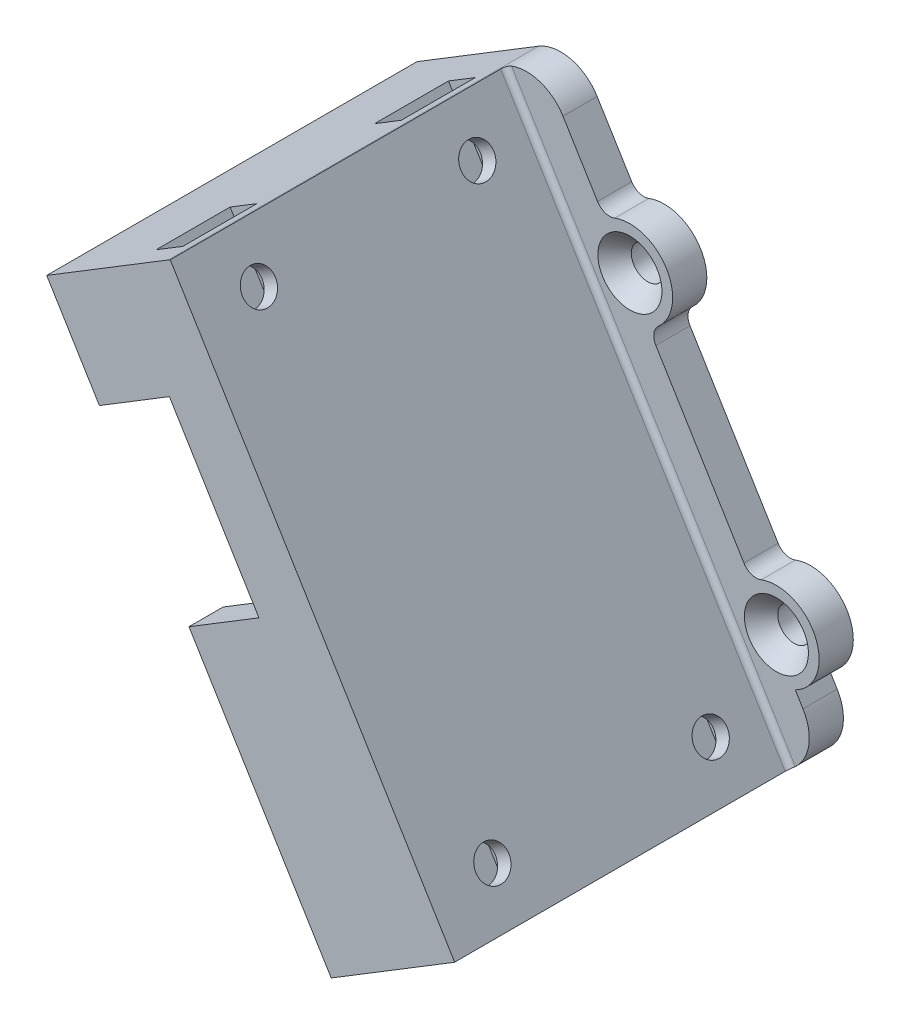
from build123d import *

# Parameters (mm, degrees)
BOSS_EXTRUDE1_DEPTH                               = 3.048
BOSS_EXTRUDE2_DEPTH                               = 29.971999999999998
BOSS_EXTRUDE3_DEPTH                               = 3.048
BOSS_EXTRUDE4_DEPTH                               = 3.048
SKETCH13_W                                        = 29.972
SKETCH13_H                                        = 48.7
BOSS_EXTRUDE5_DEPTH                               = 3.048
CSK_FOR_4_FLAT_HEAD_MACHINE_SCREW_100_D           = 2.9464
CSK_FOR_4_FLAT_HEAD_MACHINE_SCREW_100_CSINK_D     = 5.715
CSK_FOR_4_FLAT_HEAD_MACHINE_SCREW_100_CSINK_ANGLE = 100
CUT_EXTRUDE1_DEPTH                                = 1.397
CUT_EXTRUDE1_DEPTH_BACK                           = 1.397
SKETCH15_R                                        = 9.184035329670005
SKETCH15_R_2                                      = 8.124741076595411
SKETCH15_R_3                                      = 8.201451240556812
SKETCH15_R_4                                      = 5.810172256980604
BOSS_EXTRUDE6_DEPTH                               = 3.048
CSK_FOR_4_FLAT_HEAD_MACHINE_SCREW1_AT_2_COUNT     = 2
CSK_FOR_4_FLAT_HEAD_MACHINE_SCREW1_AT_2_PITCH     = 35.474094707842795
CSK_FOR_4_FLAT_HEAD_MACHINE_SCREW1_AT_3_COUNT     = 2
CSK_FOR_4_FLAT_HEAD_MACHINE_SCREW1_AT_3_PITCH     = 43.70753982500484
CSK_FOR_4_FLAT_HEAD_MACHINE_SCREW1_AT_4_COUNT     = 2
CSK_FOR_4_FLAT_HEAD_MACHINE_SCREW1_AT_4_PITCH     = 25.069264350610375
CUT_EXTRUDE2_DEPTH                                = 3.048
FILLET3_R                                         = 3.8099999999999996
FILLET4_R                                         = 1.27
SKETCH21_W                                        = 2.540000000000001
SKETCH21_H                                        = 33.02
CUT_EXTRUDE3_DEPTH                                = 77.47
FILLET5_R                                         = 0.508
FILLET6_R                                         = 0.508
SKETCH22_W                                        = 123.04970813102194
SKETCH22_H                                        = 134.7131875745612
CUT_EXTRUDE4_DEPTH                                = 77.47


with BuildPart() as part:
    # Sketch2 → Boss-Extrude1 (new body)
    with BuildSketch(Plane.XY):
        Polygon((-47.58059551455695, 48.12489153745831), (-22.21147896413696, 6.554494312375088), (5.701292889255674, 23.58878817682547), (-19.667823661164306, 65.1591854019087), align=None)
        Polygon((-38.85234269167306, 46.0124042215628), (-20.098991648241444, 15.282747135258976), (-3.0269599336282123, 25.701275492720985), (-21.78031097705982, 56.430932579024805), align=None, mode=Mode.SUBTRACT)
    extrude(amount=BOSS_EXTRUDE1_DEPTH)

    # Sketch3 → Boss-Extrude2 (add)
    with BuildSketch(Plane.XY.offset(3.048)):
        Polygon((2.4490708476218597, 21.604058524728963), (-22.920045702798127, 63.17445574981219), (-44.328373472923126, 50.10962118955482), (-18.95925692250314, 8.539223964471608), align=None)
        Polygon((-38.85234269167306, 46.0124042215628), (-20.098991648241444, 15.282747135258976), (-3.0269599336282087, 25.701275492720985), (-21.78031097705982, 56.430932579024805), align=None, mode=Mode.SUBTRACT)
    extrude(amount=BOSS_EXTRUDE2_DEPTH)

    # Sketch4 → Boss-Extrude3 (add)
    with BuildSketch(Plane.XY.offset(33.02)):
        Polygon((-38.85234269167306, 46.0124042215628), (-37.46131723814535, 43.733039051773666), (-20.389285523532113, 54.15156740923567), (-21.78031097705982, 56.430932579024805), align=None)
        Polygon((-29.47566716995725, 30.647575678410885), (-12.403635455344016, 41.0661040358729), (-3.0269599336282087, 25.701275492720985), (-20.098991648241444, 15.282747135258976), align=None)
    extrude(amount=-BOSS_EXTRUDE3_DEPTH)

    # Sketch12 → Boss-Extrude4 (add)
    with BuildSketch(Plane.XY.offset(3.048)):
        Polygon((2.4490708476218597, 21.604058524728963), (5.701292889255674, 23.58878817682547), (8.120429940678708, 25.065112049236276), (-17.248686609741274, 66.6355092743195), (-22.920045702798127, 63.17445574981219), align=None)
    extrude(amount=-BOSS_EXTRUDE4_DEPTH)

    # Sketch13 → Boss-Extrude5 (add)
    with BuildSketch(Plane(origin=(11.391019162328917, 6.95158362794815, 0), x_dir=(0, 0, -1), z_dir=(0.8536015857306615, 0.5209264178731006, 0))):
        with Locations((-18.034000000000002, 41.515472911157566)):
            Rectangle(SKETCH13_W, SKETCH13_H)
    extrude(amount=BOSS_EXTRUDE5_DEPTH)

    # CSK for #4 Flat Head Machine Screw (100)2 (through all)
    with Locations(Plane(origin=(-10.017308607796087, -6.113250932309213, 0), x_dir=(0, 0, 1), z_dir=(-0.8536015857306615, -0.5209264178731007, 0))):
        with Locations((27.397617355, 61.471448289), (7.925915452, 61.471448289), (7.925915452, 21.515515982), (27.397617355, 21.515515982)):
            CounterSinkHole(CSK_FOR_4_FLAT_HEAD_MACHINE_SCREW_100_D / 2, CSK_FOR_4_FLAT_HEAD_MACHINE_SCREW_100_CSINK_D / 2, counter_sink_angle=CSK_FOR_4_FLAT_HEAD_MACHINE_SCREW_100_CSINK_ANGLE)

    # Sketch14 → Cut-Extrude1 (cut, two sides: drawn at the far end of the back side and taken through both)
    with BuildSketch(Plane(origin=(11.607833965104508, 7.083898938087922, 0), x_dir=(0, 0, -1), z_dir=(0.8536015857306615, 0.5209264178731005, 0)).offset(-CUT_EXTRUDE1_DEPTH_BACK)):
        Polygon((-30.697174143874744, 19.61051598216394), (-30.697174143874744, 14.979833054183299), (-24.09806056703731, 14.979833054183299), (-24.09806056703731, 19.610515982163985), (-24.098060567037347, 23.42051598216399), (-27.39761735545604, 25.325515982163957), (-30.697174143874758, 23.420515982163952), align=None)
        Polygon((-27.39761735545604, 57.661448288693826), (-24.098060567037333, 59.56644828869383), (-24.098060567037336, 63.37644828869381), (-24.098060567037336, 70.99644828869384), (-30.69717414387474, 70.99644828869384), (-30.69717414387474, 63.37644828869381), (-30.69717414387474, 59.56644828869381), align=None)
        Polygon((-7.925915451689084, 57.661448288693826), (-4.626358663270381, 59.56644828869382), (-4.626358663270402, 63.37644828869381), (-4.626358663270402, 70.99644828869384), (-11.225472240107786, 70.99644828869384), (-11.225472240107786, 63.376448288693766), (-11.225472240107747, 59.566448288693785), align=None)
        Polygon((-7.925915451689081, 25.325515982163946), (-11.225472240107791, 23.42051598216395), (-11.225472240107791, 19.610515982163946), (-11.225472240107791, 14.979833054183299), (-4.626358663270366, 14.979833054183299), (-4.626358663270366, 19.610515982163953), (-4.6263586632703655, 23.420515982163952), align=None)
    extrude(amount=CUT_EXTRUDE1_DEPTH + CUT_EXTRUDE1_DEPTH_BACK, mode=Mode.SUBTRACT)

    # Sketch15 → Boss-Extrude6 (add)
    with BuildSketch(Plane(origin=(0, 0, 0), x_dir=(-1, 0, 0), z_dir=(0, 0, -1))):
        with Locations((9.758086495919196, 54.36124573948299)):
            Circle(SKETCH15_R)
        with Locations((39.927818301519274, 35.58488100974543)):
            Circle(SKETCH15_R_2)
        with Locations((25.610425726235285, 18.04643091882164)):
            Circle(SKETCH15_R_3)
        with Locations((-3.4576236647063787, 32.70568986323082)):
            Circle(SKETCH15_R_4)
    extrude(amount=-BOSS_EXTRUDE6_DEPTH)

    # Sketch19 → CSK for #4 Flat Head Machine Screw1 (revolve, cut)
    with BuildSketch(Plane(origin=(3.764373982237945, 32.86032278852424, 3.048), x_dir=(0, -1, 0), z_dir=(1, 0, 0))):
        Polygon((0, 0), (-7.5e-16, 3.0480000000000023), (1.4731999999999932, 3.0480000000000023), (1.4731999999999934, 1.59245498611605), (2.857499999999999, -1.73e-15), align=None)
    csk_for_4_flat_head_machine_screw1 = revolve(axis=Axis((3.764373982237945, 32.86032278852424, 9.39799999999999), (0, 0, -1)), mode=Mode.SUBTRACT)

    # CSK for #4 Flat Head Machine Screw1 at 2: CSK for #4 Flat Head Machine Screw1 ×2
    with Locations(*[Vector(-0.8506492202713736, -0.5257336816789507, 0) * (i * CSK_FOR_4_FLAT_HEAD_MACHINE_SCREW1_AT_2_PITCH) for i in range(1, CSK_FOR_4_FLAT_HEAD_MACHINE_SCREW1_AT_2_COUNT)]):
        add(csk_for_4_flat_head_machine_screw1, mode=Mode.SUBTRACT)

    # CSK for #4 Flat Head Machine Screw1 at 3: CSK for #4 Flat Head Machine Screw1 ×2
    with Locations(*[Vector(-0.997755305773639, 0.06696528802709796, 0) * (i * CSK_FOR_4_FLAT_HEAD_MACHINE_SCREW1_AT_3_PITCH) for i in range(1, CSK_FOR_4_FLAT_HEAD_MACHINE_SCREW1_AT_3_COUNT)]):
        add(csk_for_4_flat_head_machine_screw1, mode=Mode.SUBTRACT)

    # CSK for #4 Flat Head Machine Screw1 at 4: CSK for #4 Flat Head Machine Screw1 ×2
    with Locations(*[Vector(-0.5210117203175807, 0.8535495224600124, 0) * (i * CSK_FOR_4_FLAT_HEAD_MACHINE_SCREW1_AT_4_PITCH) for i in range(1, CSK_FOR_4_FLAT_HEAD_MACHINE_SCREW1_AT_4_COUNT)]):
        add(csk_for_4_flat_head_machine_screw1, mode=Mode.SUBTRACT)

    # Sketch20 → Cut-Extrude2 (cut)
    with BuildSketch(Plane(origin=(0, 0, 0), x_dir=(-1, 0, 0), z_dir=(0, 0, -1))):
        with BuildLine():
            Line((14.542293121824187, 62.20075286029573), (11.563953125478477, 57.32037886408755))
            ThreePointArc((11.563953125478477, 57.32037886408755), (6.044784522535942, 56.24291105550805), (7.610320649443919, 50.84186897257834))
            Line((7.610320649443919, 50.84186897257834), (-1.4954062126549716, 35.92102291440944))
            ThreePointArc((-1.4954062126549716, 35.92102291440944), (-7.016596023871767, 34.845052440620755), (-5.448804035753348, 29.442897530407524))
            Line((-5.448804035753348, 29.442897530407524), (-6.484295885760952, 27.746117611303884))
            Line((-6.484295885760952, 27.746117611303884), (-6.762670750549963, 27.28996638176623))
            Line((-6.762670750549963, 27.28996638176623), (-14.061950278269341, 31.74448896114331))
            Line((-14.061950278269341, 31.74448896114331), (8.559037851416688, 68.81174198534737))
            Line((8.559037851416688, 68.81174198534737), (14.542293121824187, 65.16034795406075))
            Line((14.542293121824187, 65.16034795406075), (14.542293121824187, 62.20075286029573))
        make_face()
        Polygon((21.78031097705982, 56.430932579024805), (38.85234269167306, 46.0124042215628), (20.098991648241444, 15.282747135258976), (3.0269599336282123, 25.701275492720985), align=None)
        with BuildLine():
            Line((22.21147896413696, 6.554494312375088), (24.781951964671258, 10.766528400207497))
            ThreePointArc((24.781951964671258, 10.766528400207497), (29.66385906245521, 12.225666721445755), (28.72915433514684, 17.23450177808784))
            Line((28.72915433514684, 17.23450177808784), (38.012718373529104, 32.44675577885475))
            ThreePointArc((38.012718373529104, 32.44675577885475), (43.097277822107074, 33.802481129765034), (41.97793801322115, 38.944252653808825))
            Line((41.97793801322115, 38.944252653808825), (47.58059551455695, 48.12489153745831))
            Line((47.58059551455695, 48.12489153745831), (51.80171473929435, 35.787210781861546))
            Line((51.80171473929435, 35.787210781861546), (47.57680035710003, 5.227667032097241))
            Line((47.57680035710003, 5.227667032097241), (22.21147896413696, 6.554494312375088))
        make_face()
    extrude(amount=-CUT_EXTRUDE2_DEPTH, mode=Mode.SUBTRACT)


with BuildPart() as body_2:
    # of the pieces the cut leaves, the one that is kept (cut_extrude2_keep)
    add(part.part.solids().sort_by_distance((-47.580595515, 48.124891537, 0))[0])

    # Fillet3
    fillet3_edges = [body_2.edges().sort_by_distance(p)[0] for p in [
        (-17.248686609741274, 66.6355092743195, 1.524),
        (-47.58059551455695, 48.12489153745831, 1.524),
        (-22.21147896413696, 6.554494312375088, 1.524),
        (8.120429940678708, 25.065112049236276, 1.524),
    ]]
    fillet(fillet3_edges, radius=FILLET3_R)

    # Fillet4
    fillet4_edges = [body_2.edges().sort_by_distance(p)[0] for p in [
        (1.4954062126549714, 35.92102291440944, 1.524),
        (-24.781951964671258, 10.766528400207495, 1.524),
        (-28.72915433514684, 17.23450177808784, 1.524),
        (-38.0127183735291, 32.44675577885475, 1.524),
        (-41.97793801322115, 38.94425265380882, 1.524),
        (-11.563953125478475, 57.320378864087544, 1.524),
        (-7.610320649443917, 50.84186897257834, 1.524),
    ]]
    fillet(fillet4_edges, radius=FILLET4_R)

    # Sketch21 → Cut-Extrude3 (cut)
    with BuildSketch(Plane(origin=(-8.941948314707059, 14.652474896780824, 0), x_dir=(0.8536015857306616, 0.5209264178731006, 0), z_dir=(0.5209264178731005, -0.8536015857306615, 0))):
        with Locations((2.2216732427396275, 16.51)):
            Rectangle(SKETCH21_W, SKETCH21_H)
    extrude(amount=-CUT_EXTRUDE3_DEPTH, mode=Mode.SUBTRACT)


with BuildPart() as cut_extrude3_piece_1:
    # of the separate pieces the step leaves, piece 1, a body of its own (cut_extrude3_pieces)
    add(body_2.part.solids().sort_by_distance((-12.188709065, 58.344117807, 0))[0])

    # Fillet6
    fillet6_edges = [cut_extrude3_piece_1.edges().sort_by_distance(p)[0] for p in [
        (-7.633709794281099, 43.97704085894782, 3.048),
    ]]
    fillet(fillet6_edges, radius=FILLET6_R)


with BuildPart() as cut_extrude3_piece_2:
    # of the separate pieces the step leaves, piece 2, a body of its own (cut_extrude3_pieces)
    add(body_2.part.solids().sort_by_distance((-42.532157132, 39.852408399, 0))[0])

    # Fillet5
    fillet5_edges = [cut_extrude3_piece_2.edges().sort_by_distance(p)[0] for p in [
        (-31.64381519771313, 29.324422577013216, 3.048),
    ]]
    fillet(fillet5_edges, radius=FILLET5_R)

    # Sketch22 → Cut-Extrude4 (cut)
    with BuildSketch(Plane(origin=(2.067982642978631, 1.2620252919381492, 0), x_dir=(0, 0, -1), z_dir=(0.8536015857306616, 0.5209264178731006, 0))):
        with Locations((-42.687564536567926, 74.45417523171726)):
            Rectangle(SKETCH22_W, SKETCH22_H)
    extrude(amount=-CUT_EXTRUDE4_DEPTH, mode=Mode.SUBTRACT)


solid = cut_extrude3_piece_1.part
